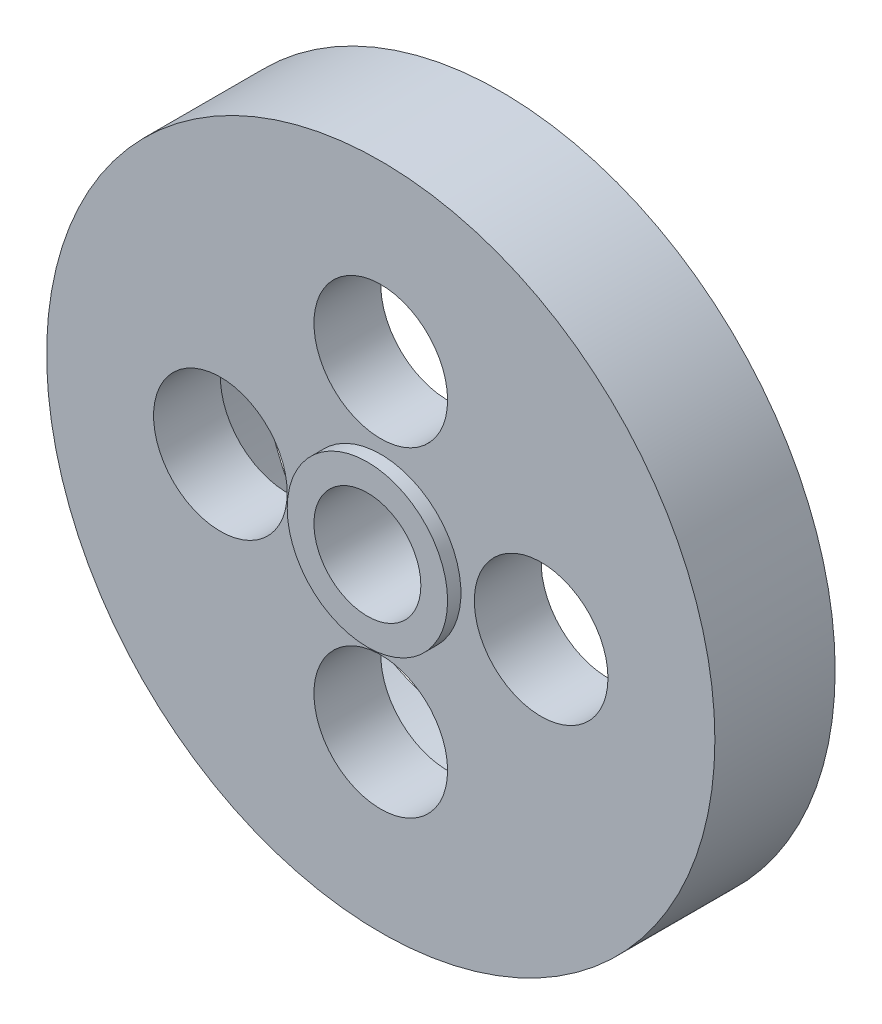
from build123d import *

# Parameters (mm, degrees)
SKETCH_2_R          = 5
CUT_EXTRUDE_1_DEPTH = 10
SKETCH_3_R          = 6
SKETCH_3_R_2        = 4
EXTRUDE_1_DEPTH     = 1


with BuildPart() as part:
    # Эскиз1 → Повернуть1 (revolve)
    with BuildSketch(Plane(origin=(0, 0, 0), x_dir=(0, 0, -1), z_dir=(1, 0, 0))):
        Polygon((7.739063178, 4), (7.739063178, 25), (16.739063178, 25), (16.739063178, 18), (12.739063178, 18), (12.739063178, 4), align=None)
    revolve(axis=Axis((0, 0, 0), (0, 0, -1)))

    # Эскиз2 → Вырез-Вытянуть1 (cut, through all)
    with BuildSketch(Plane.XY.offset(-7.739063178)):
        with Locations((0, 12)):
            Circle(SKETCH_2_R)
        with Locations((12, 0)):
            Circle(SKETCH_2_R)
        with Locations((0, -12)):
            Circle(SKETCH_2_R)
        with Locations((-12, 0)):
            Circle(SKETCH_2_R)
    extrude(amount=-CUT_EXTRUDE_1_DEPTH, mode=Mode.SUBTRACT)

    # Эскиз3 → Бобышка-Вытянуть1 (add)
    with BuildSketch(Plane.XY.offset(-7.739063178)):
        Circle(SKETCH_3_R)
        Circle(SKETCH_3_R_2, mode=Mode.SUBTRACT)
    extrude(amount=EXTRUDE_1_DEPTH)


solid = part.part
